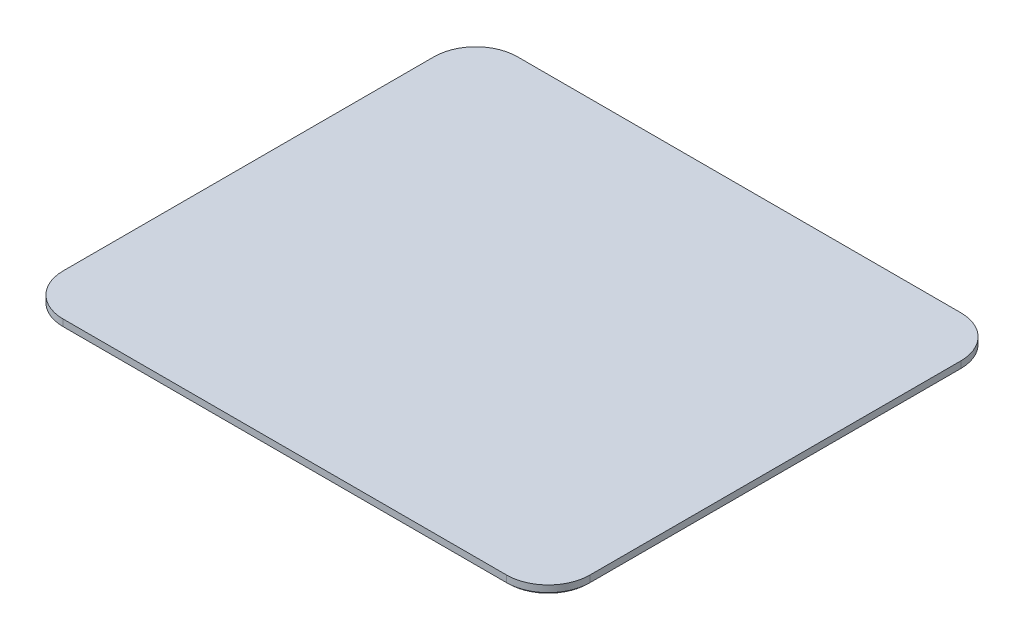
from build123d import *

# Parameters (mm, degrees)
BOSS_EXTRUDE1_DEPTH            = 5
CHAMFER1_SIZE                  = 2
SKETCH4_W                      = 200
SKETCH4_H                      = 10
BOSS_EXTRUDE3_DEPTH            = 20
CUT_EXTRUDE1_REACH             = 318
SKETCH5_R                      = 2
CUT_EXTRUDE1_DIRECTION_2_REACH = 318
BOSS_EXTRUDE4_DEPTH            = 5


with BuildPart() as part:
    # Sketch1 → Boss-Extrude1 (new body, symmetric)
    with BuildSketch(Plane(origin=(0, 0, 0), x_dir=(1, 0, 0), z_dir=(0, 1, 0))):
        with BuildLine():
            Line((-266, 272.5), (266, 272.5))
            ThreePointArc((266, 272.5), (301.355339059, 257.855339059), (316, 222.5))
            Line((316, 222.5), (316, -222.5))
            ThreePointArc((316, -222.5), (301.355339059, -257.855339059), (266, -272.5))
            Line((266, -272.5), (-266, -272.5))
            ThreePointArc((-266, -272.5), (-301.355339059, -257.855339059), (-316, -222.5))
            Line((-316, -222.5), (-316, 222.5))
            ThreePointArc((-316, 222.5), (-301.355339059, 257.855339059), (-266, 272.5))
        make_face()
    extrude(amount=BOSS_EXTRUDE1_DEPTH, both=True)

    # Chamfer1
    chamfer1_edges = [part.edges().sort_by_distance(p)[0] for p in [
        (316, -5, 0),
        (301.355339059, -5, 257.855339059),
        (0, -5, 272.5),
        (-301.355339059, -5, 257.855339059),
        (-316, -5, 0),
        (-301.355339059, -5, -257.855339059),
        (0, -5, -272.5),
        (301.355339059, -5, -257.855339059),
    ]]
    chamfer(chamfer1_edges, length=CHAMFER1_SIZE)

    # Sketch4 → Boss-Extrude3 (add)
    with BuildSketch(Plane(origin=(0, 5, 0), x_dir=(1, 0, 0), z_dir=(0, 1, 0))):
        with Locations((0, 267.5)):
            Rectangle(SKETCH4_W, SKETCH4_H)
    extrude(amount=-BOSS_EXTRUDE3_DEPTH)

    # Sketch5 → Cut-Extrude1 (cut, up to next)
    with BuildSketch(Plane(origin=(0, 0, 0), x_dir=(0, 0, -1), z_dir=(1, 0, 0)), mode=Mode.PRIVATE) as cut_extrude1_sk1:
        with Locations((267.5, -9.996889361)):
            Circle(SKETCH5_R)
    cut_extrude1_tool1 = extrude(cut_extrude1_sk1.sketch, amount=-CUT_EXTRUDE1_REACH, mode=Mode.PRIVATE) & part.part
    add(cut_extrude1_tool1.solids().sort_by_distance((0, -9.996889, -267.5))[0], mode=Mode.SUBTRACT)
    # Sketch5 → Cut-Extrude1 (cut, up to next)
    with BuildSketch(Plane(origin=(0, 0, 0), x_dir=(0, 0, -1), z_dir=(1, 0, 0)), mode=Mode.PRIVATE) as cut_extrude1_sk2:
        with BuildLine():
            Line((267.5, -15), (267.5, -14.996889361))
            ThreePointArc((267.5, -14.996889361), (263.964466094, -13.532423267), (262.5, -9.996889361))
            Line((262.5, -9.996889361), (262.5, -15))
            Line((262.5, -15), (267.5, -15))
        make_face()
    cut_extrude1_tool2 = extrude(cut_extrude1_sk2.sketch, amount=-CUT_EXTRUDE1_REACH, mode=Mode.PRIVATE) & part.part
    add(cut_extrude1_tool2.solids().sort_by_distance((0, -13.883283, -263.620838))[0], mode=Mode.SUBTRACT)

    # Sketch5 → Cut-Extrude1 direction 2 (cut, up to next)
    with BuildSketch(Plane(origin=(0, 0, 0), x_dir=(0, 0, -1), z_dir=(1, 0, 0)), mode=Mode.PRIVATE) as cut_extrude1_direction_2_sk1:
        with Locations((267.5, -9.996889361)):
            Circle(SKETCH5_R)
    cut_extrude1_direction_2_tool1 = extrude(cut_extrude1_direction_2_sk1.sketch, amount=CUT_EXTRUDE1_DIRECTION_2_REACH, mode=Mode.PRIVATE) & part.part
    add(cut_extrude1_direction_2_tool1.solids().sort_by_distance((0, -9.996889, -267.5))[0], mode=Mode.SUBTRACT)
    # Sketch5 → Cut-Extrude1 direction 2 (cut, up to next)
    with BuildSketch(Plane(origin=(0, 0, 0), x_dir=(0, 0, -1), z_dir=(1, 0, 0)), mode=Mode.PRIVATE) as cut_extrude1_direction_2_sk2:
        with BuildLine():
            Line((267.5, -15), (267.5, -14.996889361))
            ThreePointArc((267.5, -14.996889361), (263.964466094, -13.532423267), (262.5, -9.996889361))
            Line((262.5, -9.996889361), (262.5, -15))
            Line((262.5, -15), (267.5, -15))
        make_face()
    cut_extrude1_direction_2_tool2 = extrude(cut_extrude1_direction_2_sk2.sketch, amount=CUT_EXTRUDE1_DIRECTION_2_REACH, mode=Mode.PRIVATE) & part.part
    add(cut_extrude1_direction_2_tool2.solids().sort_by_distance((0, -13.883283, -263.620838))[0], mode=Mode.SUBTRACT)

    # Sketch6 → Boss-Extrude4 (add)
    with BuildSketch(Plane.XZ.offset(5)):
        with BuildLine():
            Line((-200, 200), (200, 200))
            ThreePointArc((200, 200), (235.355339059, 185.355339059), (250, 150))
            Line((250, 150), (250, -150))
            ThreePointArc((250, -150), (235.355339059, -185.355339059), (200, -200))
            Line((200, -200), (-200, -200))
            ThreePointArc((-200, -200), (-235.355339059, -185.355339059), (-250, -150))
            Line((-250, -150), (-250, 150))
            ThreePointArc((-250, 150), (-235.355339059, 185.355339059), (-200, 200))
        make_face()
    extrude(amount=BOSS_EXTRUDE4_DEPTH)


solid = part.part
